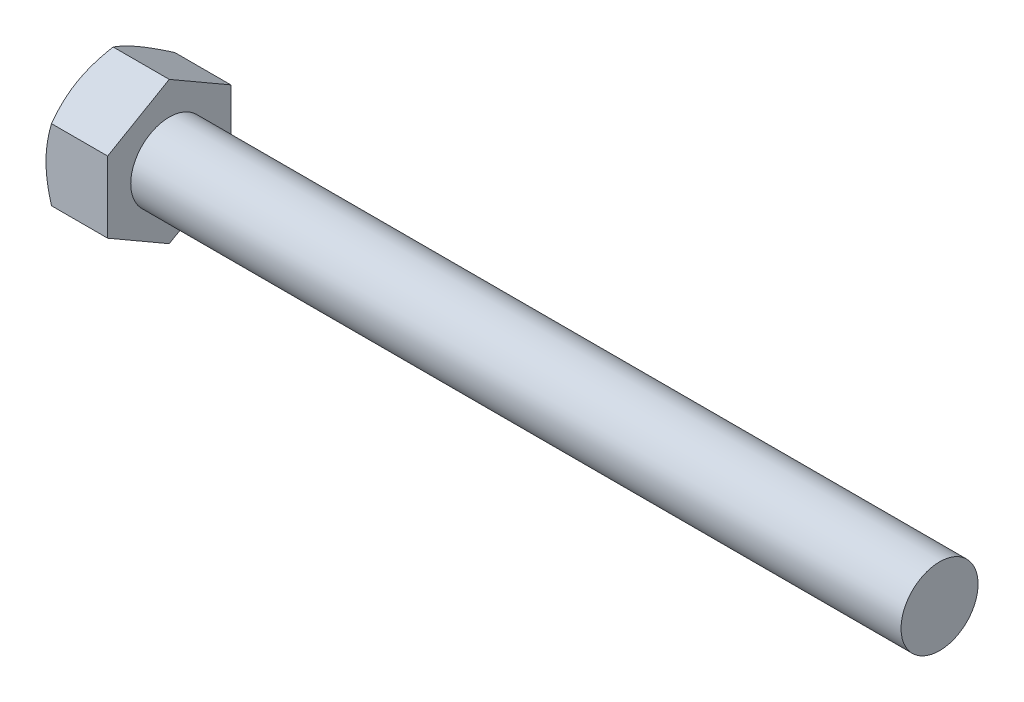
from build123d import *

# Parameters (mm, degrees)
HEX_DIE_START = 1e-06
SKETCH2_R     = 1.866050808
HEX_DIE_DEPTH = 1.599999
SKETCH4_R     = 1.4
INDENT_DEPTH  = 0.2


with BuildPart() as part:
    # BodySke → Base-Revolve (revolve)
    with BuildSketch(Plane.XY):
        Polygon((1.6, 1), (1.6, 1.847575058), (0.142937526, 1.847575058), (0, 1.6), (0, 0), (21.6, 0), (21.6, 1), align=None)
    revolve(axis=Axis((-25.4, 0, 0), (1, 0, 0)))

    # Sketch2 → Hex-Die (cut)
    with BuildSketch(Plane(origin=(0, 0, 0), x_dir=(0, 0, -1), z_dir=(1, 0, 0)).offset(HEX_DIE_START)):
        Circle(SKETCH2_R)
        Polygon((-1.6, 0.923760435), (0, 1.847520869), (1.6, 0.923760435), (1.6, -0.923760435), (0, -1.847520869), (-1.6, -0.923760435), align=None, mode=Mode.SUBTRACT)
    extrude(amount=HEX_DIE_DEPTH, mode=Mode.SUBTRACT)

    # Sketch4 → Indent (cut)
    with BuildSketch(Plane(origin=(0, 0, 0), x_dir=(0, 0, -1), z_dir=(1, 0, 0))):
        Circle(SKETCH4_R)
    extrude(amount=INDENT_DEPTH, mode=Mode.SUBTRACT)


solid = part.part
